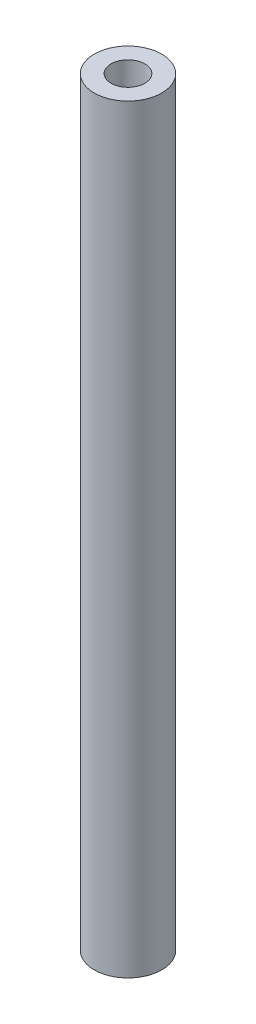
from build123d import *

# Parameters (mm, degrees)
SKETCH_1_R      = 4
SKETCH_1_R_2    = 2
EXTRUDE_1_DEPTH = 90


with BuildPart() as part:
    # 草图1 → 凸台-拉伸1 (new body)
    with BuildSketch(Plane(origin=(0, 0, 0), x_dir=(1, 0, 0), z_dir=(0, 1, 0))):
        Circle(SKETCH_1_R)
        Circle(SKETCH_1_R_2, mode=Mode.SUBTRACT)
    extrude(amount=EXTRUDE_1_DEPTH)


solid = part.part
